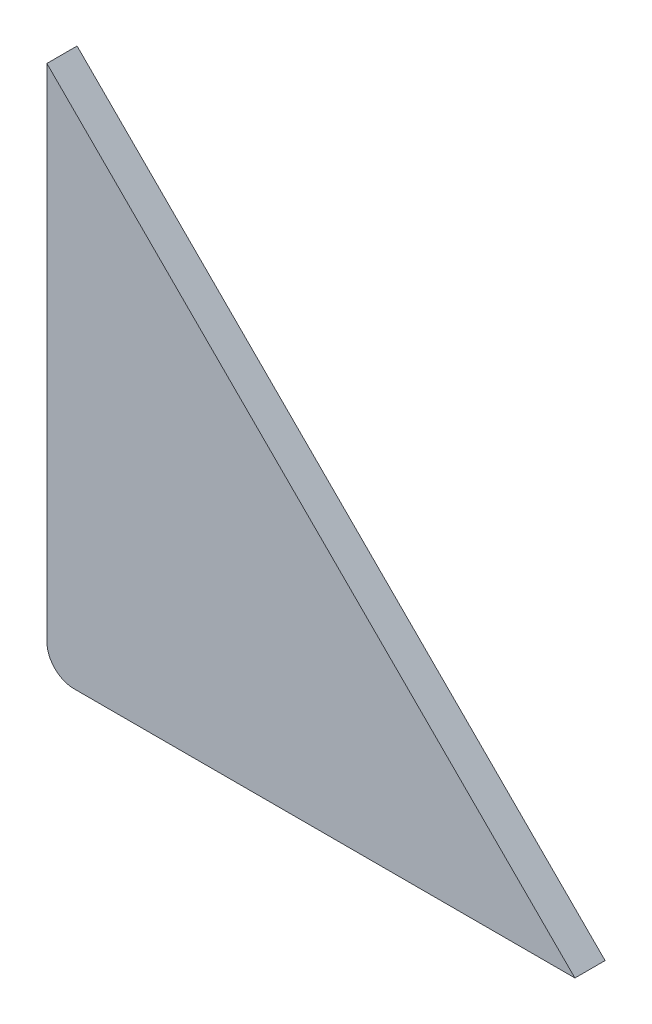
from build123d import *

# Parameters (mm, degrees)
BOSS_EXTRUDE1_DEPTH = 2


with BuildPart() as part:
    # Sketch1 → Boss-Extrude1 (new body)
    with BuildSketch(Plane.XY):
        with BuildLine():
            Line((0, 1.8), (0, 35))
            Line((0, 35), (35, 0))
            Line((35, 0), (1.8, 0))
            ThreePointArc((1.8, 0), (0.527207794, 0.527207794), (0, 1.8))
        make_face()
    extrude(amount=BOSS_EXTRUDE1_DEPTH)


solid = part.part
